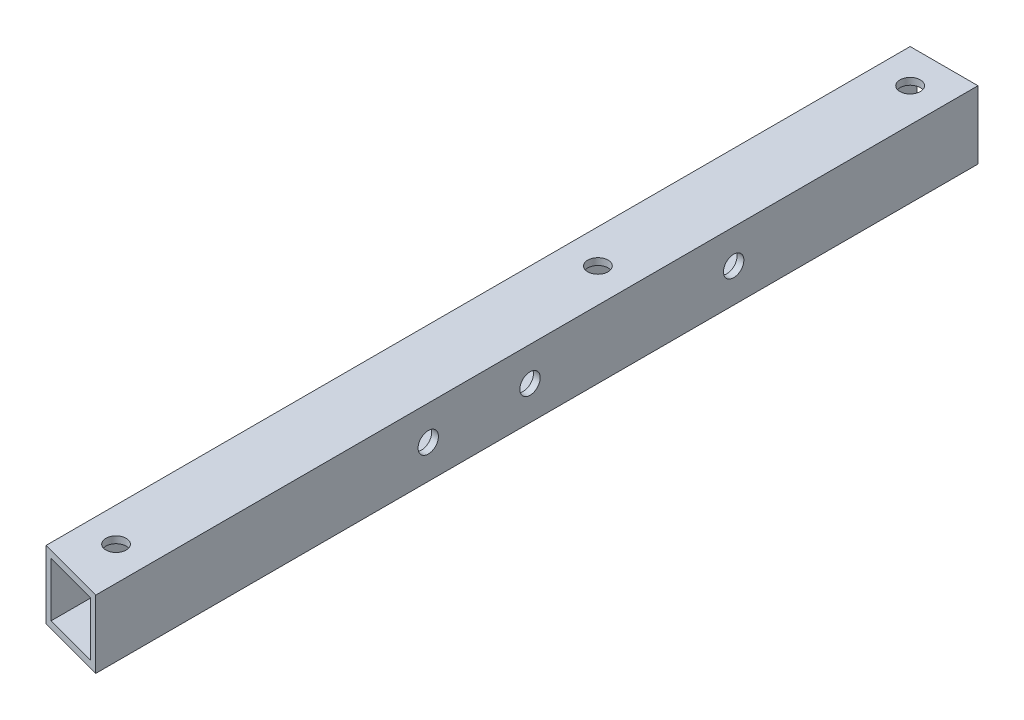
from build123d import *

# Parameters (mm, degrees)
SKETCH_1_W          = 10
SKETCH_1_H          = 10
SKETCH_1_W_2        = 8
SKETCH_1_H_2        = 8
EXTRUDE_1_DEPTH     = 130
SKETCH_2_R          = 1.5
CUT_EXTRUDE_1_DEPTH = 11
SKETCH_3_R          = 1.5
CUT_EXTRUDE_2_DEPTH = 11


with BuildPart() as part:
    # 草图1 → 拉伸-薄壁1 (new body)
    with BuildSketch(Plane.XY):
        Rectangle(SKETCH_1_W, SKETCH_1_H)
        Rectangle(SKETCH_1_W_2, SKETCH_1_H_2, mode=Mode.SUBTRACT)
    extrude(amount=EXTRUDE_1_DEPTH)

    # 草图2 → 切除-拉伸1 (cut, through all)
    with BuildSketch(Plane.XZ.offset(5)):
        with Locations((0, 51)):
            Circle(SKETCH_2_R)
        with Locations((0, 122)):
            Circle(SKETCH_2_R)
        with Locations((0, 5)):
            Circle(SKETCH_2_R)
        Polygon((5, 130), (-5, 127.320508076), (-5, 130), align=None)
    extrude(amount=-CUT_EXTRUDE_1_DEPTH, mode=Mode.SUBTRACT)

    # 草图3 → 切除-拉伸2 (cut, through all)
    with BuildSketch(Plane(origin=(5, 0, 0), x_dir=(0, 0, -1), z_dir=(1, 0, 0))):
        with Locations((-36, 0)):
            Circle(SKETCH_3_R)
        with Locations((-66, 0)):
            Circle(SKETCH_3_R)
        with Locations((-81, 0)):
            Circle(SKETCH_3_R)
    extrude(amount=-CUT_EXTRUDE_2_DEPTH, mode=Mode.SUBTRACT)


solid = part.part
